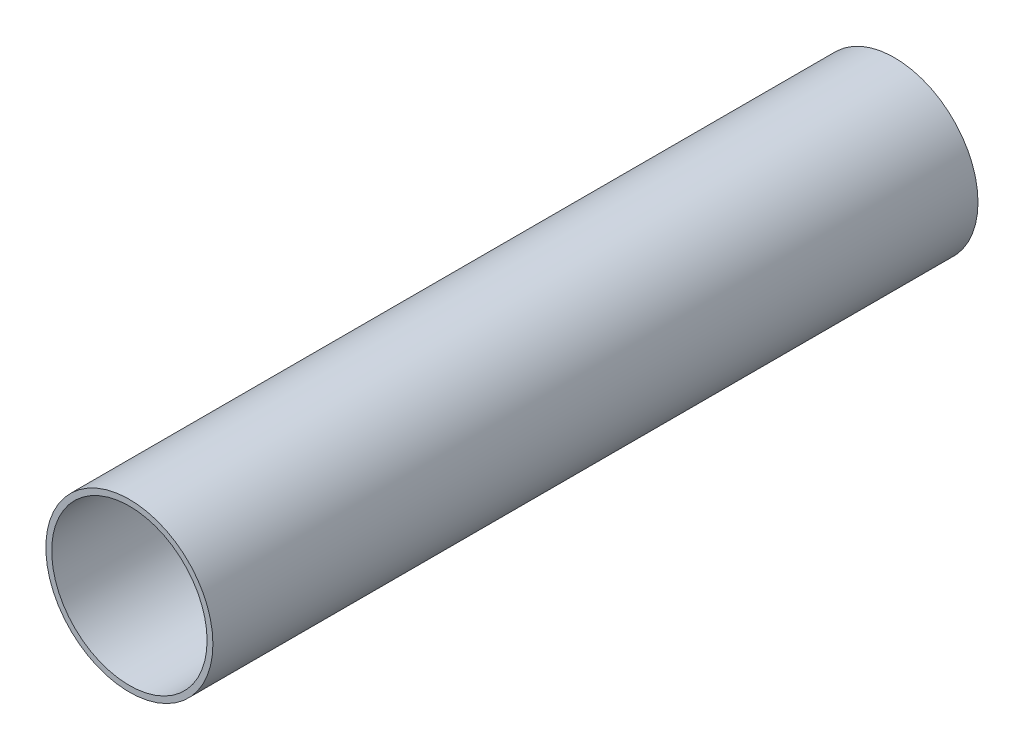
from build123d import *

# Parameters (mm, degrees)
SKETCH1_R           = 22.1869
SKETCH1_R_2         = 20.6375
BOSS_EXTRUDE1_DEPTH = 203.2


with BuildPart() as part:
    # Sketch1 → Boss-Extrude1 (new body)
    with BuildSketch(Plane.XY):
        Circle(SKETCH1_R)
        Circle(SKETCH1_R_2, mode=Mode.SUBTRACT)
    extrude(amount=BOSS_EXTRUDE1_DEPTH)


solid = part.part
